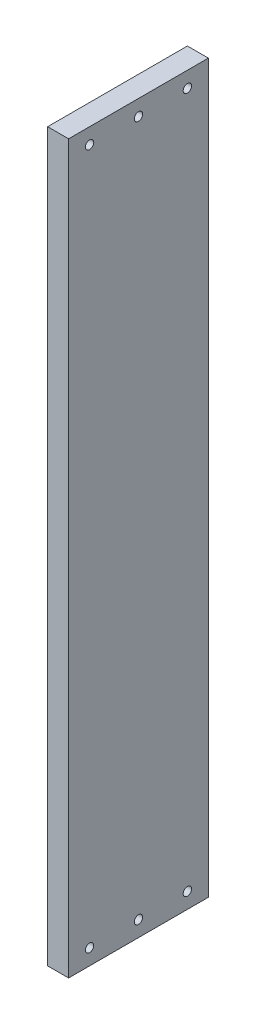
from build123d import *

# Parameters (mm, degrees)
SKETCH1_W           = 19.05
SKETCH1_H           = 127
BOSS_EXTRUDE1_DEPTH = 660.4
SKETCH2_R           = 3.81
CUT_EXTRUDE1_DEPTH  = 37.846


with BuildPart() as part:
    # Sketch1 → Boss-Extrude1 (new body)
    with BuildSketch(Plane(origin=(0, 0, 0), x_dir=(1, 0, 0), z_dir=(0, 1, 0))):
        with Locations((9.525, 63.5)):
            Rectangle(SKETCH1_W, SKETCH1_H)
    extrude(amount=BOSS_EXTRUDE1_DEPTH)

    # Sketch2 → Cut-Extrude1 (cut)
    with BuildSketch(Plane(origin=(19.05, 0, 0), x_dir=(0, 0, -1), z_dir=(1, 0, 0))):
        with Locations((107.95, 646.176)):
            Circle(SKETCH2_R)
        with Locations((63.5, 646.176)):
            Circle(SKETCH2_R)
        with Locations((19.05, 646.176)):
            Circle(SKETCH2_R)
        with Locations((19.05, 14.224)):
            Circle(SKETCH2_R)
        with Locations((63.5, 14.224)):
            Circle(SKETCH2_R)
        with Locations((107.95, 14.224)):
            Circle(SKETCH2_R)
    extrude(amount=-CUT_EXTRUDE1_DEPTH, mode=Mode.SUBTRACT)


solid = part.part
